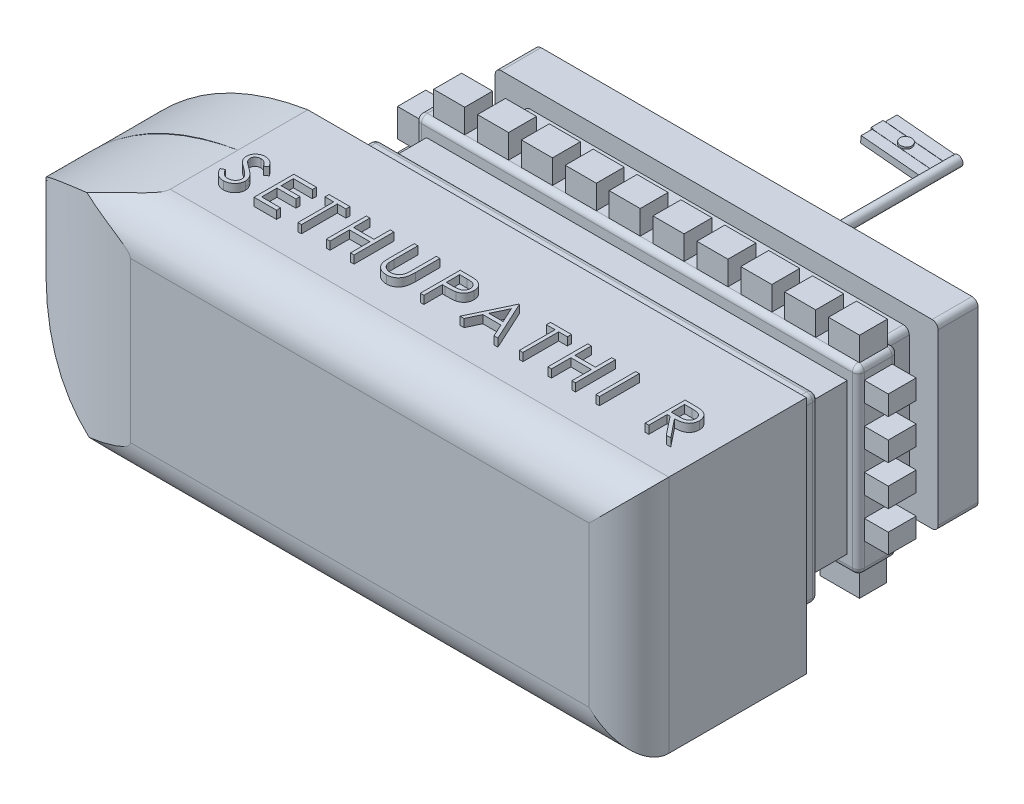
from build123d import *

# Parameters (mm, degrees)
SKETCH1_W                 = 250
SKETCH1_H                 = 120
BOSS_EXTRUDE1_DEPTH       = 54
CUT_EXTRUDE1_DEPTH        = 156
BOSS_EXTRUDE2_DEPTH       = 35
SKETCH5_W                 = 222.085242178
SKETCH5_H                 = 90.906469494
BOSS_EXTRUDE3_DEPTH       = 55
SKETCH6_W                 = 210.95738208
SKETCH6_H                 = 75.327465356
BOSS_EXTRUDE4_DEPTH       = 20
SKETCH7_W                 = 222.085242178
SKETCH7_H                 = 90.906469494
BOSS_EXTRUDE5_DEPTH       = 20
SKETCH8_W                 = 193.152805922
SKETCH8_H                 = 71.989107326
BOSS_EXTRUDE6_DEPTH       = 20
SKETCH9_W                 = 222.085242178
SKETCH9_H                 = 90.906469494
BOSS_EXTRUDE7_DEPTH       = 20
FILLET1_R                 = 3
FILLET2_R                 = 20
FILLET4_R                 = 3
SKETCH10_W                = 15.579004138
SKETCH10_H                = 14
BOSS_EXTRUDE8_DEPTH       = 12
SKETCH11_W                = 14
SKETCH11_H                = 9.842557519
BOSS_EXTRUDE10_DEPTH      = 12
SKETCH12_W                = 19.762944654
SKETCH12_H                = 13.420726207
BOSS_EXTRUDE11_DEPTH      = 12
SKETCH13_W                = 14.198177512
SKETCH13_H                = 14.148676433
BOSS_EXTRUDE12_DEPTH      = 12
SKETCH16_R                = 28.070682622
BOSS_EXTRUDE13_DEPTH      = 5
BOSS_EXTRUDE15_DEPTH      = 96
SKETCH18_W                = 6
SKETCH18_H                = 3.422347316
BOSS_EXTRUDE16_DEPTH      = 29
SKETCH20_W                = 6
SKETCH20_H                = 3.422347316
BOSS_EXTRUDE18_DEPTH      = 30
SKETCH21_W                = 6
SKETCH21_H                = 3.422347316
BOSS_EXTRUDE19_DEPTH      = 29
SKETCH22_W                = 29
SKETCH22_H                = 0.096691538
SKETCH22_H_2              = 0.117685001
CUT_EXTRUDE2_DEPTH        = 29
SKETCH23_R                = 2.974178126
BOSS_EXTRUDE21_DEPTH      = 1
BOSS_EXTRUDE21_DEPTH_BACK = 5
SKETCH24_W                = 1.794871795
SKETCH24_H                = 20
BOSS_EXTRUDE22_DEPTH      = 4


with BuildPart() as part:
    # Sketch1 → Boss-Extrude1 (new body)
    with BuildSketch(Plane.XY):
        with BuildLine():
            add(Edge.make_bspline(
                [(-216.889279026, 0), (-184.916721751, 49.409463433), (-125, 60)],
                knots=[0, 0, 0, 1, 1, 1], degree=2))
            Line((-125, 60), (-125, -60))
            add(Edge.make_bspline(
                [(-216.889279026, 0), (-185.803518335, -45.858958305), (-125, -60)],
                knots=[0, 0, 0, 1, 1, 1], degree=2))
        make_face()
        Rectangle(SKETCH1_W, SKETCH1_H)
    extrude(amount=BOSS_EXTRUDE1_DEPTH)

    # Sketch3 → Cut-Extrude1 (cut)
    with BuildSketch(Plane.XZ.offset(60)):
        with BuildLine():
            Line((-216.889279026, 0), (-216.889279026, 54))
            Line((-216.889279026, 54), (-125, 54))
            add(Edge.make_bspline(
                [(-216.889279026, 0), (-186.224283917, 48.717673116), (-125, 54)],
                knots=[0, 0, 0, 1, 1, 1], degree=2))
        make_face()
    extrude(amount=-CUT_EXTRUDE1_DEPTH, mode=Mode.SUBTRACT)

    # Sketch4 → Boss-Extrude2 (add)
    with BuildSketch(Plane(origin=(0, 0, 0), x_dir=(-1, 0, 0), z_dir=(0, 0, -1))):
        with BuildLine():
            Line((-125, 60), (125, 60))
            add(Edge.make_bspline(
                [(125, 60), (183.356410548, 50.590790383), (216.889279026, 0)],
                knots=[0, 0, 0, 1, 1, 1], degree=2))
            add(Edge.make_bspline(
                [(125, -60), (178.477086532, -48.464579156), (216.889279026, 0)],
                knots=[0, 0, 0, 1, 1, 1], degree=2))
            Line((125, -60), (-125, -60))
            Line((-125, -60), (-125, 60))
        make_face()
        with BuildLine():
            Line((-117.162944143, 53.79912982), (117.162944143, 53.79912982))
            add(Edge.make_bspline(
                [(117.162944143, 53.79912982), (176.840628855, 38.459327505), (203.960252912, 0)],
                knots=[0, 0, 0, 1, 1, 1], degree=2))
            add(Edge.make_bspline(
                [(117.162944143, -53.79912982), (166.587976574, -40.985232524), (203.960252912, 0)],
                knots=[0, 0, 0, 1, 1, 1], degree=2))
            Line((117.162944143, -53.79912982), (-117.162944143, -53.79912982))
            Line((-117.162944143, -53.79912982), (-117.162944143, 53.79912982))
        make_face(mode=Mode.SUBTRACT)
    extrude(amount=BOSS_EXTRUDE2_DEPTH)

    # Sketch5 → Boss-Extrude3 (add)
    with BuildSketch(Plane(origin=(0, 0, 0), x_dir=(-1, 0, 0), z_dir=(0, 0, -1))):
        Rectangle(SKETCH5_W, SKETCH5_H)
    extrude(amount=BOSS_EXTRUDE3_DEPTH)

    # Sketch6 → Boss-Extrude4 (add)
    with BuildSketch(Plane(origin=(0, 0, -55), x_dir=(-1, 0, 0), z_dir=(0, 0, -1))):
        Rectangle(SKETCH6_W, SKETCH6_H)
    extrude(amount=BOSS_EXTRUDE4_DEPTH)

    # Sketch7 → Boss-Extrude5 (add)
    with BuildSketch(Plane(origin=(0, 0, -75), x_dir=(-1, 0, 0), z_dir=(0, 0, -1))):
        Rectangle(SKETCH7_W, SKETCH7_H)
    extrude(amount=BOSS_EXTRUDE5_DEPTH)

    # Sketch8 → Boss-Extrude6 (add)
    with BuildSketch(Plane(origin=(0, 0, -95), x_dir=(-1, 0, 0), z_dir=(0, 0, -1))):
        Rectangle(SKETCH8_W, SKETCH8_H)
    extrude(amount=BOSS_EXTRUDE6_DEPTH)

    # Sketch9 → Boss-Extrude7 (add)
    with BuildSketch(Plane(origin=(0, 0, -115), x_dir=(-1, 0, 0), z_dir=(0, 0, -1))):
        Rectangle(SKETCH9_W, SKETCH9_H)
    extrude(amount=BOSS_EXTRUDE7_DEPTH)

    # Fillet1
    fillet1_edges = [part.edges().sort_by_distance(p)[0] for p in [
        (-96.576402961, -35.994553663, -105),
        (-96.576402961, 35.994553663, -105),
        (96.576402961, 35.994553663, -105),
        (96.576402961, -35.994553663, -105),
        (-111.042621089, -45.453234747, -27.5),
        (-111.042621089, 45.453234747, -27.5),
        (111.042621089, 45.453234747, -27.5),
        (111.042621089, -45.453234747, -27.5),
        (-111.042621089, 0, -55),
        (0, 45.453234747, -55),
        (111.042621089, 0, -55),
        (0, -45.453234747, -55),
        (-111.042621089, 0, -75),
        (-111.042621089, -45.453234747, -85),
        (0, 45.453234747, -75),
        (-111.042621089, 45.453234747, -85),
        (111.042621089, 0, -75),
        (111.042621089, 45.453234747, -85),
        (0, -45.453234747, -75),
        (111.042621089, -45.453234747, -85),
        (-111.042621089, 0, -95),
        (0, 45.453234747, -95),
        (111.042621089, 0, -95),
        (0, -45.453234747, -95),
    ]]
    fillet(fillet1_edges, radius=FILLET1_R)

    # Fillet2
    fillet2_edges = [part.edges().sort_by_distance(p)[0] for p in [
        (0, -60, 54),
        (125, 0, 54),
        (0, 60, 54),
    ]]
    fillet(fillet2_edges, radius=FILLET2_R)

    # Fillet4
    fillet4_edges = [part.edges().sort_by_distance(p)[0] for p in [
        (-111.042621089, -45.453234747, -125),
        (-111.042621089, 45.453234747, -125),
        (111.042621089, 45.453234747, -125),
        (111.042621089, -45.453234747, -125),
    ]]
    fillet(fillet4_edges, radius=FILLET4_R)

    # Sketch10 → Boss-Extrude8 (add)
    with BuildSketch(Plane(origin=(0, 45.453234747, 0), x_dir=(1, 0, 0), z_dir=(0, 1, 0))):
        with Locations((-97.132795966, 85)):
            Rectangle(SKETCH10_W, SKETCH10_H)
        with Locations((-75.132795966, 85)):
            Rectangle(SKETCH10_W, SKETCH10_H)
        with Locations((-53.132795966, 85)):
            Rectangle(SKETCH10_W, SKETCH10_H)
        with Locations((-31.132795966, 85)):
            Rectangle(SKETCH10_W, SKETCH10_H)
        with Locations((-9.132795966, 85)):
            Rectangle(SKETCH10_W, SKETCH10_H)
        with Locations((12.867204034, 85)):
            Rectangle(SKETCH10_W, SKETCH10_H)
        with Locations((34.867204034, 85)):
            Rectangle(SKETCH10_W, SKETCH10_H)
        with Locations((56.867204034, 85)):
            Rectangle(SKETCH10_W, SKETCH10_H)
        with Locations((78.867204034, 85)):
            Rectangle(SKETCH10_W, SKETCH10_H)
        with Locations((100.867204034, 85)):
            Rectangle(SKETCH10_W, SKETCH10_H)
    extrude(amount=BOSS_EXTRUDE8_DEPTH)

    # Sketch11 → Boss-Extrude10 (add)
    with BuildSketch(Plane(origin=(111.042621089, 0, 0), x_dir=(0, 0, -1), z_dir=(1, 0, 0))):
        with Locations((85, 14.171023705)):
            Rectangle(SKETCH11_W, SKETCH11_H)
        with Locations((85, 34.171023706)):
            Rectangle(SKETCH11_W, SKETCH11_H)
        with Locations((85, -5.828976295)):
            Rectangle(SKETCH11_W, SKETCH11_H)
        with Locations((85, -25.828976295)):
            Rectangle(SKETCH11_W, SKETCH11_H)
    extrude(amount=BOSS_EXTRUDE10_DEPTH)

    # Sketch12 → Boss-Extrude11 (add)
    with BuildSketch(Plane.XZ.offset(45.453234747)):
        with Locations((63.161148762, -85.289636896)):
            Rectangle(SKETCH12_W, SKETCH12_H)
        with Locations((98.161148762, -85.289636896)):
            Rectangle(SKETCH12_W, SKETCH12_H)
        with Locations((28.161148762, -85.289636896)):
            Rectangle(SKETCH12_W, SKETCH12_H)
        with Locations((-6.838851238, -85.289636896)):
            Rectangle(SKETCH12_W, SKETCH12_H)
        with Locations((-41.838851238, -85.289636896)):
            Rectangle(SKETCH12_W, SKETCH12_H)
        with Locations((-76.838851238, -85.289636896)):
            Rectangle(SKETCH12_W, SKETCH12_H)
    extrude(amount=BOSS_EXTRUDE11_DEPTH)

    # Sketch13 → Boss-Extrude12 (add)
    with BuildSketch(Plane.ZY.offset(111.042621089)):
        with Locations((-85.099088756, 33.863443782)):
            Rectangle(SKETCH13_W, SKETCH13_H)
        with Locations((-85.099088756, 13.863443783)):
            Rectangle(SKETCH13_W, SKETCH13_H)
        with Locations((-85.099088756, -6.136556217)):
            Rectangle(SKETCH13_W, SKETCH13_H)
        with Locations((-85.099088756, -26.136556218)):
            Rectangle(SKETCH13_W, SKETCH13_H)
    extrude(amount=BOSS_EXTRUDE12_DEPTH)

    # Sketch16 → Boss-Extrude13 (add)
    with BuildSketch(Plane(origin=(0, 0, -135), x_dir=(-1, 0, 0), z_dir=(0, 0, -1))):
        Circle(SKETCH16_R)
    extrude(amount=BOSS_EXTRUDE13_DEPTH)

    # Sketch17 → Boss-Extrude15 (add)
    with BuildSketch(Plane(origin=(0, 0, -140), x_dir=(-1, 0, 0), z_dir=(0, 0, -1))):
        with BuildLine():
            Line((1.971883519, -1.536774346), (1.657956073, 1.871144478))
            ThreePointArc((1.657956073, 1.871144478), (-2.489460091, -0.229321732), (1.971883519, -1.536774346))
        make_face()
    extrude(amount=BOSS_EXTRUDE15_DEPTH)

    # Sketch18 → Boss-Extrude16 (add)
    with BuildSketch(Plane(origin=(-1.814919796, 0.167185066, 0), x_dir=(0, 0, 1), z_dir=(-0.995784036, 0.091728693, 0))):
        with Locations((-233, 0)):
            Rectangle(SKETCH18_W, SKETCH18_H)
    extrude(amount=BOSS_EXTRUDE16_DEPTH)

    # Sketch20 → Boss-Extrude18 (add)
    with BuildSketch(Plane(origin=(-1.814919796, 0.167185066, 0), x_dir=(0, 0, 1), z_dir=(-0.995784036, 0.091728693, 0))):
        with Locations((-227, 0)):
            Rectangle(SKETCH20_W, SKETCH20_H)
    extrude(amount=BOSS_EXTRUDE18_DEPTH)

    # Sketch21 → Boss-Extrude19 (add)
    with BuildSketch(Plane(origin=(-1.814919796, 0.167185066, 0), x_dir=(0, 0, 1), z_dir=(-0.995784036, 0.091728693, 0))):
        with Locations((-221, 0)):
            Rectangle(SKETCH21_W, SKETCH21_H)
    extrude(amount=BOSS_EXTRUDE19_DEPTH)

    # Sketch22 → Cut-Extrude2 (cut)
    with BuildSketch(Plane(origin=(-0.156963723, -1.703959412, 0), x_dir=(0.995784036, -0.091728693, 0), z_dir=(-0.091728693, -0.995784036, 0))):
        with Locations((-16.322603828, -223.570989022)):
            Rectangle(SKETCH22_W, SKETCH22_H)
        with Locations((-16.322603828, -230.058842501)):
            Rectangle(SKETCH22_W, SKETCH22_H_2)
    extrude(amount=-CUT_EXTRUDE2_DEPTH, mode=Mode.SUBTRACT)

    # Sketch23 → Boss-Extrude21 (add, two sides)
    with BuildSketch(Plane(origin=(0.156963723, 1.703959412, 0), x_dir=(0.995784036, -0.091728693, 0), z_dir=(0.091728693, 0.995784036, 0))) as boss_extrude21_sk:
        with Locations((-17.192397014, 226.82631355)):
            Circle(SKETCH23_R)
    extrude(amount=BOSS_EXTRUDE21_DEPTH)
    extrude(boss_extrude21_sk.sketch, amount=-BOSS_EXTRUDE21_DEPTH_BACK)

    # Sketch24 → Boss-Extrude22 (add)
    with BuildSketch(Plane(origin=(0, 60, 0), x_dir=(1, 0, 0), z_dir=(0, 1, 0))):
        with BuildLine():
            Line((-117.501059218, -16.604846752), (-115.81035409, -15.591224957))
            add(Edge.make_bspline(
                [(-115.81035409, -15.591224957), (-115.65310702, -15.854450014), (-115.351827702, -16.358779064), (-114.849248507, -17.040253581), (-114.328489015, -17.619465906), (-113.785692823, -18.09304652), (-113.224173119, -18.465897301), (-112.640264241, -18.729910054), (-112.035933894, -18.894572771), (-111.624654914, -18.914573265), (-111.419328449, -18.92455829)],
                knots=[0, 0, 0, 0, 0.000919434, 0.0017616, 0.002535875, 0.003251599, 0.003917218, 0.004550193, 0.005167258, 0.005782448, 0.005782448, 0.005782448, 0.005782448], degree=3))
            add(Edge.make_bspline(
                [(-111.419328449, -18.92455829), (-111.24397496, -18.919674447), (-110.896336257, -18.909992217), (-110.384552012, -18.816959063), (-109.887513142, -18.674032612), (-109.415463783, -18.469341574), (-108.974917414, -18.221693085), (-108.588593441, -17.92257207), (-108.254615651, -17.587679466), (-107.981420711, -17.214064297), (-107.771820509, -16.812252019), (-107.610722976, -16.399818011), (-107.521322555, -15.970283335), (-107.507855392, -15.681080691), (-107.501059218, -15.535135213)],
                knots=[0, 0, 0, 0, 0.000525588, 0.00104198, 0.001555442, 0.002074145, 0.002582012, 0.003067631, 0.003535078, 0.00399665, 0.004450083, 0.004891334, 0.005321142, 0.005759015, 0.005759015, 0.005759015, 0.005759015], degree=3))
            add(Edge.make_bspline(
                [(-107.501059218, -15.535135213), (-107.509483851, -15.368616072), (-107.526609898, -15.030106991), (-107.671361212, -14.530680403), (-107.899071194, -14.036437146), (-108.109143444, -13.730715628), (-108.218206654, -13.571994188)],
                knots=[0, 0, 0, 0, 0.000498746, 0.001013877, 0.001548054, 0.002124824, 0.002124824, 0.002124824, 0.002124824], degree=3))
            add(Edge.make_bspline(
                [(-108.218206654, -13.571994188), (-108.307753021, -13.45744091), (-108.495744417, -13.216950632), (-108.818930203, -12.858977858), (-109.198165142, -12.48972975), (-109.62047117, -12.095106567), (-110.101231678, -11.693462015), (-110.625388903, -11.265643284), (-111.20632524, -10.827919986), (-111.613750935, -10.534362469), (-111.823975885, -10.382891623)],
                knots=[0, 0, 0, 0, 0.00043611, 0.000915559, 0.00144533, 0.002023698, 0.002649032, 0.003324168, 0.004053346, 0.004830683, 0.004830683, 0.004830683, 0.004830683], degree=3))
            add(Edge.make_bspline(
                [(-111.823975885, -10.382891623), (-112.03439872, -10.23301398), (-112.436711158, -9.946459338), (-112.999331628, -9.521177716), (-113.502442846, -9.132355604), (-113.943808654, -8.776332678), (-114.323234922, -8.453060651), (-114.643711556, -8.165643855), (-114.89707474, -7.906309222), (-115.037963772, -7.738072983), (-115.101219475, -7.662539059)],
                knots=[0, 0, 0, 0, 0.000774989, 0.001481721, 0.00211562, 0.00268251, 0.003182685, 0.003610922, 0.003973585, 0.004269083, 0.004269083, 0.004269083, 0.004269083], degree=3))
            add(Edge.make_bspline(
                [(-115.101219475, -7.662539059), (-115.189634019, -7.544818849), (-115.363513086, -7.313306256), (-115.593033117, -6.951449926), (-115.788114047, -6.581031266), (-115.941041659, -6.201054897), (-116.069820053, -5.816855304), (-116.1564368, -5.423419614), (-116.210673354, -5.022513223), (-116.216227562, -4.752721791), (-116.219007936, -4.617667264)],
                knots=[0, 0, 0, 0, 0.000441542, 0.000868352, 0.001284093, 0.001695526, 0.002095886, 0.002498286, 0.002902299, 0.003307263, 0.003307263, 0.003307263, 0.003307263], degree=3))
            add(Edge.make_bspline(
                [(-116.219007936, -4.617667264), (-116.211549599, -4.406068553), (-116.196792342, -3.987393903), (-116.071989386, -3.375789157), (-115.875001422, -2.791866773), (-115.599030634, -2.241407723), (-115.243274332, -1.738744975), (-114.83158305, -1.278096478), (-114.3412317, -0.890847437), (-113.80321671, -0.552492818), (-113.214323155, -0.287658959), (-112.597232278, -0.08788193), (-111.950963295, 0.025313828), (-111.513231098, 0.041558199), (-111.291123321, 0.049800684)],
                knots=[0, 0, 0, 0, 0.000634279, 0.001255002, 0.001864411, 0.002478974, 0.003094711, 0.003707286, 0.004325481, 0.0049625, 0.005609731, 0.006257197, 0.006904018, 0.007570288, 0.007570288, 0.007570288, 0.007570288], degree=3))
            add(Edge.make_bspline(
                [(-111.291123321, 0.049800684), (-111.055442748, 0.041671818), (-110.586749309, 0.025506097), (-109.89732522, -0.115051224), (-109.233549698, -0.347626492), (-108.699588185, -0.61156168), (-108.28168669, -0.87516977), (-107.962985361, -1.115283052), (-107.640028499, -1.391712244), (-107.310211043, -1.70519365), (-106.979121561, -2.058603656), (-106.641844691, -2.449521878), (-106.297591726, -2.87555934), (-106.076129668, -3.179699345), (-105.96259768, -3.335615982)],
                knots=[0, 0, 0, 0, 0.000706504, 0.001405011, 0.002100617, 0.002811932, 0.003186505, 0.003581538, 0.004007839, 0.004461255, 0.004945898, 0.005459984, 0.006009973, 0.006588507, 0.006588507, 0.006588507, 0.006588507], degree=3))
            Line((-105.96259768, -3.335615982), (-107.585193834, -4.565583931))
            add(Edge.make_bspline(
                [(-107.585193834, -4.565583931), (-107.683170591, -4.439362843), (-107.871850917, -4.196290539), (-108.158305127, -3.855883021), (-108.428297401, -3.544931709), (-108.694299686, -3.274845264), (-108.942263294, -3.030833073), (-109.182932107, -2.821920177), (-109.412842685, -2.646059632), (-109.702653603, -2.458382146), (-110.066754851, -2.272344983), (-110.523809344, -2.11492168), (-111.001445201, -2.020321326), (-111.326757381, -2.007813397), (-111.491443834, -2.001481367)],
                knots=[0, 0, 0, 0, 0.000479298, 0.000923016, 0.001334586, 0.001714244, 0.002059912, 0.002378012, 0.002669683, 0.002927498, 0.003413067, 0.003891997, 0.00437365, 0.00486748, 0.00486748, 0.00486748, 0.00486748], degree=3))
            add(Edge.make_bspline(
                [(-111.491443834, -2.001481367), (-111.698052533, -2.008405367), (-112.096477947, -2.021757648), (-112.662136439, -2.167586135), (-113.171244582, -2.397196766), (-113.608687811, -2.71899664), (-113.972899108, -3.100259456), (-114.236358873, -3.538995771), (-114.394931242, -4.023466643), (-114.414281411, -4.361418964), (-114.424136141, -4.533532649)],
                knots=[0, 0, 0, 0, 0.000618559, 0.001192833, 0.001739602, 0.002284532, 0.002811737, 0.003311255, 0.00380792, 0.004323379, 0.004323379, 0.004323379, 0.004323379], degree=3))
            add(Edge.make_bspline(
                [(-114.424136141, -4.533532649), (-114.421889703, -4.640683955), (-114.417393154, -4.85516178), (-114.354680025, -5.172027049), (-114.27411243, -5.488091845), (-114.146440249, -5.801935176), (-113.970181371, -6.119045799), (-113.738723223, -6.444884299), (-113.447218583, -6.782322635), (-113.223921369, -7.001793342), (-113.106027167, -7.117667264)],
                knots=[0, 0, 0, 0, 0.000320913, 0.000642351, 0.000965979, 0.001298535, 0.001655376, 0.002052192, 0.00249544, 0.002991216, 0.002991216, 0.002991216, 0.002991216], degree=3))
            add(Edge.make_bspline(
                [(-113.106027167, -7.117667264), (-113.062247896, -7.156735983), (-112.95823837, -7.249554317), (-112.768090222, -7.401510206), (-112.516988518, -7.588954619), (-112.211490226, -7.820882142), (-111.845962445, -8.089919068), (-111.420364981, -8.392625424), (-110.939441936, -8.738828046), (-110.598173845, -8.980871136), (-110.417725885, -9.108853162)],
                knots=[0, 0, 0, 0, 0.000176009, 0.000418156, 0.000729859, 0.001116078, 0.00156882, 0.002091376, 0.002682861, 0.003346536, 0.003346536, 0.003346536, 0.003346536], degree=3))
            add(Edge.make_bspline(
                [(-110.417725885, -9.108853162), (-110.200663523, -9.266803788), (-109.780352344, -9.572653284), (-109.18230903, -10.032171455), (-108.640058698, -10.481587276), (-108.151697535, -10.918030745), (-107.712400915, -11.338191276), (-107.327042511, -11.747123735), (-106.991695766, -12.141898436), (-106.630671661, -12.64802744), (-106.261769835, -13.269633636), (-105.944961221, -14.031223571), (-105.745199236, -14.795773973), (-105.71907629, -15.30964161), (-105.706187423, -15.563180085)],
                knots=[0, 0, 0, 0, 0.000805328, 0.001559407, 0.002262175, 0.002917624, 0.003523983, 0.004085167, 0.004602754, 0.00507641, 0.005949072, 0.006764531, 0.007544805, 0.008304725, 0.008304725, 0.008304725, 0.008304725], degree=3))
            add(Edge.make_bspline(
                [(-105.706187423, -15.563180085), (-105.709942498, -15.742485028), (-105.717379727, -16.097612934), (-105.802870663, -16.619070516), (-105.928125893, -17.125532629), (-106.116910087, -17.610738986), (-106.347328134, -18.083566201), (-106.639706693, -18.531611346), (-106.978607749, -18.964790767), (-107.36737212, -19.371553575), (-107.792777276, -19.744960409), (-108.242398388, -20.077126474), (-108.716971376, -20.354088322), (-109.213921757, -20.580093134), (-109.733363681, -20.756856091), (-110.275122446, -20.884929629), (-110.840091082, -20.963533692), (-111.224093834, -20.971692329), (-111.419328449, -20.975840341)],
                knots=[0, 0, 0, 0, 0.000537397, 0.001064358, 0.001581309, 0.002099934, 0.00262312, 0.003156559, 0.003701564, 0.004271165, 0.00484178, 0.005397906, 0.005945555, 0.006487013, 0.007033077, 0.007588929, 0.008154969, 0.008740398, 0.008740398, 0.008740398, 0.008740398], degree=3))
            add(Edge.make_bspline(
                [(-111.419328449, -20.975840341), (-111.570387552, -20.972919304), (-111.870603323, -20.967114016), (-112.314657506, -20.915792413), (-112.749740872, -20.843180393), (-113.170393913, -20.727899993), (-113.582036265, -20.588031553), (-113.982877605, -20.415812509), (-114.373112198, -20.209428501), (-114.754926958, -19.973456932), (-115.127350812, -19.698841248), (-115.486890629, -19.378992697), (-115.845343118, -19.022732669), (-116.19212824, -18.620386593), (-116.534260493, -18.17845469), (-116.864994262, -17.692802214), (-117.191175506, -17.166074478), (-117.395835322, -16.795416845), (-117.501059218, -16.604846752)],
                knots=[0, 0, 0, 0, 0.000453008, 0.000900311, 0.001339648, 0.001775021, 0.002207064, 0.002643174, 0.003082237, 0.003530275, 0.00398862, 0.004468403, 0.00497267, 0.005503712, 0.00606066, 0.006648525, 0.00726559, 0.007918574, 0.007918574, 0.007918574, 0.007918574], degree=3))
        make_face()
        Polygon((-96.526700244, -0.463019829), (-85.244648962, -0.463019829), (-85.244648962, -2.51430188), (-94.731828449, -2.51430188), (-94.731828449, -8.668148034), (-85.244648962, -8.668148034), (-85.244648962, -10.719430085), (-94.731828449, -10.719430085), (-94.731828449, -18.411737777), (-85.244648962, -18.411737777), (-85.244648962, -20.463019829), (-96.526700244, -20.463019829), align=None)
        Polygon((-78.885674603, -2.51430188), (-78.885674603, -0.463019829), (-68.37285409, -0.463019829), (-68.37285409, -2.51430188), (-72.731828449, -2.51430188), (-72.731828449, -20.463019829), (-74.526700244, -20.463019829), (-74.526700244, -2.51430188), align=None)
        Polygon((-60.219007936, -0.463019829), (-58.424136141, -0.463019829), (-58.424136141, -8.668148034), (-48.167725885, -8.668148034), (-48.167725885, -0.463019829), (-46.37285409, -0.463019829), (-46.37285409, -20.463019829), (-48.167725885, -20.463019829), (-48.167725885, -10.719430085), (-58.424136141, -10.719430085), (-58.424136141, -20.463019829), (-60.219007936, -20.463019829), align=None)
        with BuildLine():
            Line((-36.167725885, -0.463019829), (-34.37285409, -0.463019829))
            Line((-34.37285409, -0.463019829), (-34.37285409, -12.446192905))
            add(Edge.make_bspline(
                [(-34.37285409, -12.446192905), (-34.373121198, -12.61579711), (-34.373628083, -12.937650315), (-34.370242289, -13.39575489), (-34.360760184, -13.803026084), (-34.354782129, -14.161033785), (-34.34148308, -14.468135199), (-34.330637098, -14.725994117), (-34.31669106, -14.933389559), (-34.299930388, -15.054423423), (-34.292725885, -15.106449316)],
                knots=[0, 0, 0, 0, 0.000508814, 0.000965562, 0.001374295, 0.001730955, 0.002039683, 0.002296375, 0.002505324, 0.002662852, 0.002662852, 0.002662852, 0.002662852], degree=3))
            add(Edge.make_bspline(
                [(-34.292725885, -15.106449316), (-34.263140406, -15.294145106), (-34.205636484, -15.658960701), (-34.059085754, -16.178436598), (-33.85441432, -16.646616359), (-33.611882647, -17.078109451), (-33.292267725, -17.460905794), (-32.90939038, -17.81354381), (-32.445517417, -18.121954123), (-31.929742528, -18.403958762), (-31.373826885, -18.630616375), (-30.805762506, -18.802007028), (-30.234088339, -18.906457884), (-29.851367396, -18.918552393), (-29.661315628, -18.92455829)],
                knots=[0, 0, 0, 0, 0.00056977, 0.001107436, 0.001613514, 0.002100025, 0.002586849, 0.003102945, 0.003656352, 0.004253321, 0.004864151, 0.005453583, 0.006031243, 0.006601056, 0.006601056, 0.006601056, 0.006601056], degree=3))
            add(Edge.make_bspline(
                [(-29.661315628, -18.92455829), (-29.498151398, -18.918422003), (-29.17276533, -18.90618487), (-28.689300011, -18.830405264), (-28.218442248, -18.693830603), (-27.757866934, -18.517603412), (-27.326147023, -18.284760034), (-26.92304164, -18.015783809), (-26.56324773, -17.700293088), (-26.234916314, -17.351148263), (-25.949002395, -16.957206548), (-25.7011673, -16.52704576), (-25.498161988, -16.054192349), (-25.397913274, -15.721881365), (-25.346411782, -15.551160854)],
                knots=[0, 0, 0, 0, 0.000489586, 0.000976344, 0.001463383, 0.001958138, 0.002452812, 0.002931741, 0.003408891, 0.003885132, 0.004366735, 0.004865658, 0.005371736, 0.005906408, 0.005906408, 0.005906408, 0.005906408], degree=3))
            add(Edge.make_bspline(
                [(-25.346411782, -15.551160854), (-25.329268209, -15.480597572), (-25.291065419, -15.323354143), (-25.25536802, -15.057518197), (-25.218187874, -14.743864689), (-25.192390331, -14.380140044), (-25.167240501, -13.967563058), (-25.15219437, -13.503984444), (-25.145239896, -12.991087525), (-25.143167437, -12.633160886), (-25.142084859, -12.446192905)],
                knots=[0, 0, 0, 0, 0.000217714, 0.000485155, 0.000803709, 0.001165375, 0.001578735, 0.002043755, 0.002556638, 0.00311755, 0.00311755, 0.00311755, 0.00311755], degree=3))
            Line((-25.142084859, -12.446192905), (-25.142084859, -0.463019829))
            Line((-25.142084859, -0.463019829), (-23.347213064, -0.463019829))
            Line((-23.347213064, -0.463019829), (-23.347213064, -12.542346752))
            add(Edge.make_bspline(
                [(-23.347213064, -12.542346752), (-23.348665181, -12.760051774), (-23.351499074, -13.184916362), (-23.376073797, -13.807495557), (-23.415256654, -14.398084021), (-23.470617156, -14.956761144), (-23.54397146, -15.481527768), (-23.625544149, -15.976983587), (-23.729427195, -16.439572116), (-23.850760916, -16.872900217), (-23.989466905, -17.285388865), (-24.169130609, -17.676866663), (-24.371556323, -18.059234661), (-24.611640054, -18.426709569), (-24.881419384, -18.780918444), (-25.186857559, -19.119713158), (-25.517852764, -19.448507708), (-25.879907391, -19.758868086), (-26.267053249, -20.043489097), (-26.678138722, -20.293762075), (-27.110005977, -20.505325603), (-27.561532412, -20.679473743), (-28.032910715, -20.81041431), (-28.52415277, -20.907986628), (-29.036376732, -20.963428329), (-29.384746196, -20.971667929), (-29.561155372, -20.975840341)],
                knots=[0, 0, 0, 0, 0.000653094, 0.001274553, 0.001868853, 0.002428562, 0.002958333, 0.003458252, 0.003934527, 0.004379743, 0.004807998, 0.005238384, 0.005670371, 0.006104877, 0.006553613, 0.007004775, 0.007472222, 0.007952407, 0.00843401, 0.008912235, 0.009394221, 0.009874873, 0.010361912, 0.010860062, 0.011375941, 0.011905166, 0.011905166, 0.011905166, 0.011905166], degree=3))
            add(Edge.make_bspline(
                [(-29.561155372, -20.975840341), (-29.753550244, -20.971355968), (-30.131028295, -20.962557645), (-30.687245822, -20.91214193), (-31.220469801, -20.817179677), (-31.736331955, -20.696265712), (-32.227809082, -20.529501499), (-32.701485907, -20.334655072), (-33.149249799, -20.095356441), (-33.57836482, -19.829108481), (-33.977363426, -19.52953912), (-34.343634301, -19.203023841), (-34.677782133, -18.854793113), (-34.974174684, -18.481076737), (-35.237722596, -18.084781268), (-35.464752386, -17.664785612), (-35.65968521, -17.221252377), (-35.760294165, -16.912948375), (-35.811155372, -16.757090341)],
                knots=[0, 0, 0, 0, 0.000577271, 0.001132603, 0.001673365, 0.002201011, 0.002720455, 0.003228654, 0.003735825, 0.004241617, 0.004742419, 0.00523051, 0.005712247, 0.006188403, 0.006659544, 0.007138206, 0.007619042, 0.00811064, 0.00811064, 0.00811064, 0.00811064], degree=3))
            add(Edge.make_bspline(
                [(-35.811155372, -16.757090341), (-35.840739133, -16.650618487), (-35.904906969, -16.419678665), (-35.973622956, -16.037470159), (-36.031389137, -15.597384915), (-36.085706612, -15.09939281), (-36.117757801, -14.543107858), (-36.14585745, -13.928771196), (-36.167923844, -13.255639986), (-36.167793715, -12.78675704), (-36.167725885, -12.542346752)],
                knots=[0, 0, 0, 0, 0.000331372, 0.000718752, 0.001163536, 0.001663054, 0.002221111, 0.002834733, 0.003508108, 0.004241292, 0.004241292, 0.004241292, 0.004241292], degree=3))
            Line((-36.167725885, -12.542346752), (-36.167725885, -0.463019829))
        make_face()
        with BuildLine():
            Line((-13.142084859, -0.463019829), (-9.219809218, -0.463019829))
            add(Edge.make_bspline(
                [(-9.219809218, -0.463019829), (-8.950032612, -0.463316378), (-8.433128653, -0.463884581), (-7.691899763, -0.4811117), (-7.018701296, -0.504121369), (-6.414984834, -0.536017902), (-5.878892845, -0.573712703), (-5.412851133, -0.6265815), (-5.013196526, -0.681783189), (-4.7737311, -0.737905512), (-4.664520757, -0.763500598)],
                knots=[0, 0, 0, 0, 0.000809305, 0.001550664, 0.00222417, 0.002829986, 0.003364343, 0.003835978, 0.004237139, 0.004573487, 0.004573487, 0.004573487, 0.004573487], degree=3))
            add(Edge.make_bspline(
                [(-4.664520757, -0.763500598), (-4.526271992, -0.801340311), (-4.253032122, -0.876128092), (-3.859311876, -1.025920798), (-3.484718473, -1.20353317), (-3.127966711, -1.405955684), (-2.793440522, -1.641873193), (-2.476148859, -1.901722438), (-2.178891829, -2.191502829), (-1.903341018, -2.5079642), (-1.650285032, -2.845793971), (-1.432401131, -3.210035284), (-1.249959833, -3.594557018), (-1.093483996, -3.999091711), (-0.980864256, -4.427036416), (-0.89602483, -4.87541763), (-0.842175529, -5.344187288), (-0.837018033, -5.664529388), (-0.834392552, -5.827603162)],
                knots=[0, 0, 0, 0, 0.000429808, 0.000849488, 0.001261681, 0.001672646, 0.002078323, 0.002488193, 0.002901844, 0.003322078, 0.003745963, 0.004166464, 0.004592954, 0.005021546, 0.005465698, 0.005918298, 0.006389933, 0.006878977, 0.006878977, 0.006878977, 0.006878977], degree=3))
            add(Edge.make_bspline(
                [(-0.834392552, -5.827603162), (-0.836800693, -5.992047601), (-0.841512384, -6.313794252), (-0.898062586, -6.784495899), (-0.974235109, -7.234315271), (-1.091361123, -7.662254988), (-1.244764969, -8.065773676), (-1.424719557, -8.451037859), (-1.641768302, -8.811493127), (-1.891167329, -9.148448084), (-2.168605011, -9.462219012), (-2.472907514, -9.750532123), (-2.802846329, -10.011699771), (-3.157372889, -10.24630745), (-3.539943454, -10.448914761), (-3.94475576, -10.630385075), (-4.375328425, -10.782791136), (-4.673285648, -10.862962915), (-4.824777167, -10.903724957)],
                knots=[0, 0, 0, 0, 0.000493049, 0.000964684, 0.0014205, 0.001860786, 0.002293126, 0.002714275, 0.003134777, 0.003553058, 0.003970283, 0.004389714, 0.004808935, 0.005231188, 0.005663175, 0.006106169, 0.006561086, 0.007031614, 0.007031614, 0.007031614, 0.007031614], degree=3))
            add(Edge.make_bspline(
                [(-4.824777167, -10.903724957), (-4.950076218, -10.930370563), (-5.224676375, -10.988765958), (-5.676920501, -11.05395714), (-6.203465564, -11.109600573), (-6.803592878, -11.151321359), (-7.476763763, -11.18703775), (-8.223342376, -11.215426858), (-9.044794246, -11.231026023), (-9.617772783, -11.231830553), (-9.916924603, -11.232250598)],
                knots=[0, 0, 0, 0, 0.000384219, 0.000842038, 0.001369866, 0.001972441, 0.002646483, 0.003392203, 0.004213674, 0.005111119, 0.005111119, 0.005111119, 0.005111119], degree=3))
            Line((-9.916924603, -11.232250598), (-11.347213064, -11.232250598))
            Line((-11.347213064, -11.232250598), (-11.347213064, -20.463019829))
            Line((-11.347213064, -20.463019829), (-13.142084859, -20.463019829))
            Line((-13.142084859, -20.463019829), (-13.142084859, -0.463019829))
        make_face()
        with BuildLine():
            Line((-11.347213064, -2.51430188), (-11.347213064, -9.180968546))
            Line((-11.347213064, -9.180968546), (-7.8456105, -9.225039059))
            add(Edge.make_bspline(
                [(-7.8456105, -9.225039059), (-7.674639496, -9.225127423), (-7.344583496, -9.225298006), (-6.867805078, -9.202525301), (-6.425466293, -9.176236543), (-6.018925862, -9.137745551), (-5.648000522, -9.083338366), (-5.312071786, -9.028414149), (-5.013744455, -8.948954934), (-4.664606159, -8.841965968), (-4.275558459, -8.659493878), (-3.852315325, -8.394637364), (-3.49362626, -8.057033317), (-3.183235993, -7.677445709), (-2.93691669, -7.25516497), (-2.756596734, -6.803342474), (-2.650647264, -6.326611905), (-2.636440443, -6.000393969), (-2.629264346, -5.835615982)],
                knots=[0, 0, 0, 0, 0.000512836, 0.00099002, 0.001431616, 0.001842229, 0.002214481, 0.002556343, 0.002862434, 0.003139919, 0.003650874, 0.00414652, 0.004631362, 0.005121292, 0.005613282, 0.006091658, 0.006575755, 0.00706986, 0.00706986, 0.00706986, 0.00706986], degree=3))
            add(Edge.make_bspline(
                [(-2.629264346, -5.835615982), (-2.636479469, -5.674824477), (-2.65082224, -5.355190865), (-2.757427173, -4.886740804), (-2.936566109, -4.439679636), (-3.184889506, -4.022690577), (-3.486267392, -3.64446884), (-3.836549352, -3.315913828), (-4.234910846, -3.051789813), (-4.605472166, -2.881313917), (-4.9346218, -2.777226629), (-5.220518714, -2.70439897), (-5.543322568, -2.646252648), (-5.903138451, -2.599169775), (-6.297177502, -2.558864282), (-6.728825016, -2.531515841), (-7.196445834, -2.51550752), (-7.521077668, -2.51471349), (-7.6893605, -2.51430188)],
                knots=[0, 0, 0, 0, 0.000482119, 0.000958394, 0.001433048, 0.001921584, 0.002409001, 0.002879579, 0.003356275, 0.003836727, 0.004097728, 0.004391182, 0.004721219, 0.005081016, 0.005479669, 0.005909271, 0.006378295, 0.006883119, 0.006883119, 0.006883119, 0.006883119], degree=3))
            Line((-7.6893605, -2.51430188), (-11.347213064, -2.51430188))
        make_face(mode=Mode.SUBTRACT)
        Polygon((16.550222833, -0.463019829), (25.780992064, -20.463019829), (23.829870269, -20.463019829), (20.8731395, -14.052763418), (11.80663309, -14.052763418), (8.765767705, -20.463019829), (6.80663309, -20.463019829), (16.293812577, -0.463019829), align=None)
        Polygon((16.401985654, -4.361257008), (12.780190782, -12.001481367), (19.927626679, -12.001481367), align=None, mode=Mode.SUBTRACT)
        Polygon((32.139966423, -2.51430188), (32.139966423, -0.463019829), (42.652786936, -0.463019829), (42.652786936, -2.51430188), (38.293812577, -2.51430188), (38.293812577, -20.463019829), (36.498940782, -20.463019829), (36.498940782, -2.51430188), align=None)
        Polygon((50.80663309, -0.463019829), (52.601504884, -0.463019829), (52.601504884, -8.668148034), (62.857915141, -8.668148034), (62.857915141, -0.463019829), (64.652786936, -0.463019829), (64.652786936, -20.463019829), (62.857915141, -20.463019829), (62.857915141, -10.719430085), (52.601504884, -10.719430085), (52.601504884, -20.463019829), (50.80663309, -20.463019829), align=None)
        with Locations((75.755351039, -10.463019829)):
            Rectangle(SKETCH24_W, SKETCH24_H)
        with BuildLine():
            Line((99.62714591, -0.463019829), (103.629549756, -0.463019829))
            add(Edge.make_bspline(
                [(103.629549756, -0.463019829), (103.896641919, -0.463908891), (104.409488459, -0.46561599), (105.144192861, -0.475134636), (105.811776272, -0.502416668), (106.41188964, -0.525894288), (106.944521954, -0.568705381), (107.411306472, -0.609623365), (107.810093315, -0.663187141), (108.05149818, -0.712932415), (108.160799756, -0.735455726)],
                knots=[0, 0, 0, 0, 0.000801292, 0.00153857, 0.002204068, 0.002805683, 0.00334004, 0.003806869, 0.004211417, 0.004546138, 0.004546138, 0.004546138, 0.004546138], degree=3))
            add(Edge.make_bspline(
                [(108.160799756, -0.735455726), (108.307123323, -0.771608671), (108.596648977, -0.84314332), (109.013506497, -0.994341039), (109.410731205, -1.169310323), (109.786673059, -1.374817296), (110.139449008, -1.612387466), (110.472696498, -1.877919594), (110.787927718, -2.16996077), (111.072394176, -2.49587415), (111.340617329, -2.837797062), (111.566838051, -3.207532816), (111.761846507, -3.594170116), (111.917106604, -4.001641074), (112.042123595, -4.425994056), (112.130273535, -4.871072895), (112.183137464, -5.334849895), (112.188519496, -5.651180803), (112.191248474, -5.811577521)],
                knots=[0, 0, 0, 0, 0.00045189, 0.000894141, 0.001328185, 0.001753129, 0.0021776, 0.00260245, 0.003030461, 0.003464654, 0.003898975, 0.004332575, 0.004762588, 0.005196355, 0.005638823, 0.006088256, 0.006555909, 0.007036945, 0.007036945, 0.007036945, 0.007036945], degree=3))
            add(Edge.make_bspline(
                [(112.191248474, -5.811577521), (112.182854199, -6.078063833), (112.166474795, -6.598047649), (112.013759917, -7.352681257), (111.763608375, -8.056620198), (111.418903867, -8.708978129), (110.979935434, -9.29703896), (110.452365199, -9.813555847), (109.835898848, -10.245783919), (109.262017042, -10.545514232), (108.755078758, -10.73747371), (108.337745542, -10.872538617), (107.882505671, -10.976892705), (107.393720902, -11.070379172), (106.869357156, -11.140960283), (106.310671217, -11.192655108), (105.717264636, -11.224963958), (105.309612811, -11.229775415), (105.09990232, -11.232250598)],
                knots=[0, 0, 0, 0, 0.000798724, 0.001558517, 0.002298565, 0.003033389, 0.003763359, 0.004491479, 0.005238522, 0.006014412, 0.006426605, 0.006863744, 0.007329213, 0.007826605, 0.008356376, 0.008915697, 0.009509512, 0.010138633, 0.010138633, 0.010138633, 0.010138633], degree=3))
            Line((105.09990232, -11.232250598), (112.447658731, -20.463019829))
            Line((112.447658731, -20.463019829), (110.228107448, -20.463019829))
            Line((110.228107448, -20.463019829), (102.880351038, -11.232250598))
            Line((102.880351038, -11.232250598), (101.422017705, -11.232250598))
            Line((101.422017705, -11.232250598), (101.422017705, -20.463019829))
            Line((101.422017705, -20.463019829), (99.62714591, -20.463019829))
            Line((99.62714591, -20.463019829), (99.62714591, -0.463019829))
        make_face()
        with BuildLine():
            Line((101.422017705, -2.51430188), (101.422017705, -9.180968546))
            Line((101.422017705, -9.180968546), (105.083876679, -9.209013418))
            add(Edge.make_bspline(
                [(105.083876679, -9.209013418), (105.25484833, -9.209089056), (105.586240085, -9.209235664), (106.065672456, -9.186414086), (106.512073094, -9.160452267), (106.923734535, -9.120741721), (107.300840679, -9.069564169), (107.643203041, -9.005547116), (107.95138048, -8.930963901), (108.3108007, -8.815526039), (108.712152307, -8.632634506), (109.148332078, -8.366545942), (109.519774008, -8.031865261), (109.833590364, -7.649159798), (110.085758544, -7.228381233), (110.263541712, -6.774573409), (110.376355668, -6.299192849), (110.389661642, -5.972460804), (110.396376679, -5.807571111)],
                knots=[0, 0, 0, 0, 0.000512836, 0.000994023, 0.001439618, 0.001854218, 0.002234405, 0.002580931, 0.002898677, 0.003185016, 0.003712221, 0.004218013, 0.004711762, 0.005204224, 0.005698249, 0.006176625, 0.006661599, 0.007155705, 0.007155705, 0.007155705, 0.007155705], degree=3))
            add(Edge.make_bspline(
                [(110.396376679, -5.807571111), (110.389507416, -5.646733546), (110.375895042, -5.328012183), (110.264759222, -4.861406981), (110.0768199, -4.421024409), (109.823549969, -4.008655923), (109.514983369, -3.634337432), (109.153167297, -3.314067986), (108.747994753, -3.049785331), (108.369302191, -2.880903157), (108.030820977, -2.777361138), (107.736937205, -2.704497345), (107.404871618, -2.645957523), (107.033011855, -2.599054318), (106.622945393, -2.55874035), (106.172598816, -2.53158733), (105.684960071, -2.515508106), (105.346977607, -2.514713312), (105.172017705, -2.51430188)],
                knots=[0, 0, 0, 0, 0.000482119, 0.000955385, 0.001429379, 0.001913111, 0.002402483, 0.002879263, 0.003357102, 0.003848504, 0.004117143, 0.004418371, 0.004756289, 0.005128001, 0.005542602, 0.005992195, 0.00648124, 0.007006095, 0.007006095, 0.007006095, 0.007006095], degree=3))
            Line((105.172017705, -2.51430188), (101.422017705, -2.51430188))
        make_face(mode=Mode.SUBTRACT)
    extrude(amount=BOSS_EXTRUDE22_DEPTH)


solid = part.part
